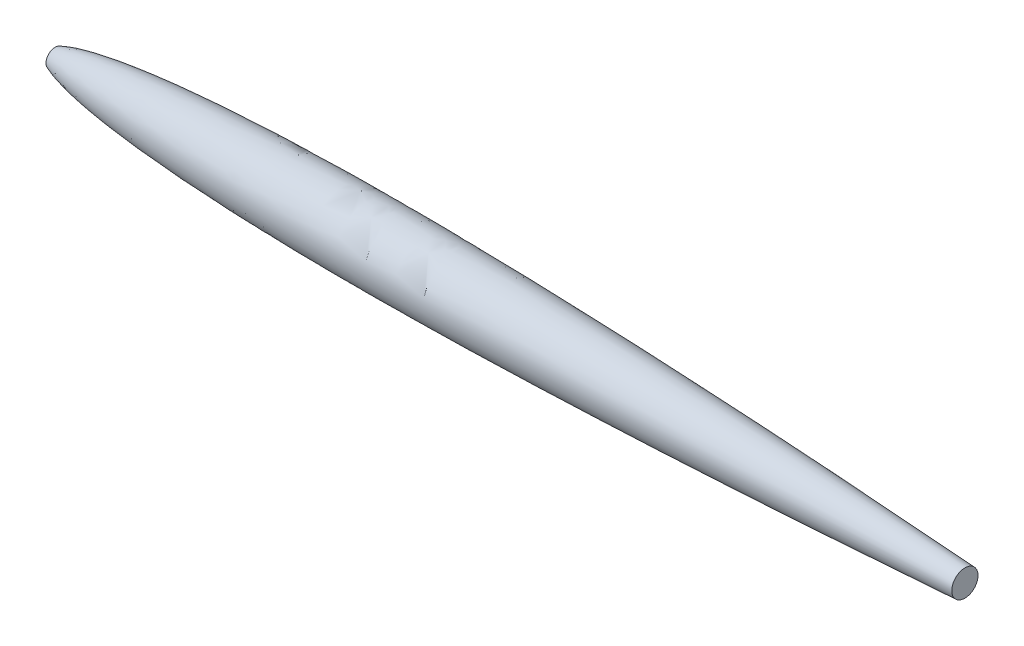
from build123d import *

# Parameters (mm, degrees)
CUTSKETCH_R        = 330
CUT_EXTRUDE1_DEPTH = 1981.000000056
SKETCH1_R          = 330
CUT_EXTRUDE2_DEPTH = 100


with BuildPart() as part:
    # rootSketch → Revolve1 (revolve)
    with BuildSketch(Plane(origin=(0, 0, 0), x_dir=(1, 0, 0), z_dir=(0, 1, 0))):
        with BuildLine():
            Line((0, 0), (10999.999999956, 0))
            add(Edge.make_bspline(
                [(0, 0), (0.000193085, 1.416582005), (0.122535707, 4.240766735), (0.673873379, 8.454686711), (2.109656818, 13.93845879), (4.130019916, 19.114733958), (6.6108994, 23.964322659), (9.99141312, 29.368131534), (13.807367772, 34.371487293), (18.005055091, 39.082436475), (24.006567174, 45.012475537), (32.38394762, 52.235407337), (43.384048479, 60.194382801), (57.076069362, 68.618071155), (73.982979094, 77.724284629), (92.789267205, 86.643497962), (113.957785626, 95.516746756), (137.455558775, 104.311070441), (166.299503437, 114.136034239), (201.291019257, 124.83380424), (243.070199966, 136.204737597), (291.673004407, 147.963968929), (341.243287097, 158.777969553), (390.608018364, 168.603047356), (439.719156269, 177.608967602), (500.651651233, 187.980684512), (573.469223954, 199.282575084), (658.612232457, 211.186619601), (758.084154261, 223.607887379), (859.684753543, 234.995657417), (963.386980877, 245.464526813), (1069.170635517, 255.102838422), (1175.032596375, 263.835414151), (1280.957756037, 271.761542521), (1386.934581972, 278.961621427), (1492.954015963, 285.502236936), (1625.576964573, 292.926255548), (1784.827209806, 300.723903315), (1970.72108882, 308.376208714), (2183.266072594, 315.387382688), (2395.855799019, 320.860371187), (2608.476211675, 324.955727138), (2821.116716449, 327.806853247), (3033.769186051, 329.526860496), (3299.591922937, 330.384071895), (3618.580812409, 329.51376865), (3990.720403141, 326.052290468), (4415.985201528, 319.209100208), (4841.201558049, 309.857365651), (5266.363404579, 298.307410519), (5691.467689334, 284.815055747), (6116.513213618, 269.590680129), (6541.499783516, 252.805736724), (6966.427609798, 234.597307498), (7391.296846876, 215.071528971), (7816.107239786, 194.306117476), (8187.764015612, 175.096544249), (8506.288418891, 157.904884619), (8771.698784382, 143.095088026), (8984.01062255, 130.95609045), (9196.305479291, 118.523403252), (9382.048027901, 107.38440154), (9541.24447253, 97.647382898), (9673.900203702, 89.404934778), (9780.020008578, 82.733097615), (9912.663326878, 74.294734048), (10032.03499694, 66.58027009), (10138.136351112, 59.627723881), (10230.971046534, 53.471278218), (10284.016761583, 49.932402374), (10337.064143493, 46.372127364), (10390.104279802, 42.790919783), (10443.152990441, 39.18744375), (10496.183419271, 35.563459924), (10549.240167305, 31.915530826), (10602.249493916, 28.248814521), (10655.332945198, 24.554271665), (10708.28973189, 20.846283715), (10761.453592237, 17.100380429), (10814.258157127, 13.357501973), (10861.039415372, 10.020132172), (10900.208423325, 7.212345677), (10934.336848159, 4.754530233), (10958.871036751, 2.983522743), (10981.803250473, 1.321442896), (10993.97273069, 0.438031797), (10999.999999956, 0)],
                knots=[0, 0, 0, 0, 0, 0.000464454, 0.000928907, 0.001393361, 0.001857814, 0.002287128, 0.002716441, 0.003486019, 0.003922473, 0.004358926, 0.005488094, 0.007117503, 0.008377929, 0.009638355, 0.011796648, 0.013954941, 0.015918589, 0.017882237, 0.021809533, 0.025977713, 0.030145893, 0.034314073, 0.038482253, 0.042518279, 0.046554305, 0.054626357, 0.062698409, 0.070770462, 0.079497478, 0.088224494, 0.09695151, 0.105678526, 0.114405542, 0.123132558, 0.131859574, 0.14058659, 0.158058513, 0.175530436, 0.193002359, 0.210474282, 0.227946206, 0.24541813, 0.262890054, 0.280361977, 0.315305825, 0.350249672, 0.38519352, 0.420137368, 0.455081215, 0.490025063, 0.524968911, 0.559912758, 0.594856606, 0.629800453, 0.664744301, 0.699688149, 0.717160073, 0.734631996, 0.75210392, 0.769575844, 0.787047768, 0.79578373, 0.804519691, 0.813255653, 0.821991615, 0.839463539, 0.84383152, 0.848199501, 0.852567482, 0.856935463, 0.861303444, 0.865671425, 0.870039406, 0.874407387, 0.878775368, 0.883143349, 0.88751133, 0.891879311, 0.896247292, 0.900615273, 0.902799263, 0.904983254, 0.907167244, 0.909351235, 0.909351235, 0.909351235, 0.909351235, 0.909351235], degree=4))
        make_face()
    revolve(axis=Axis((0, 0, 0), (1, 0, 0)))

    # cutSketch → Cut-Extrude1 (cut, through all)
    with BuildSketch(Plane(origin=(9020, 0, 0), x_dir=(0, 0, -1), z_dir=(1, 0, 0))):
        Circle(CUTSKETCH_R)
    extrude(amount=CUT_EXTRUDE1_DEPTH, mode=Mode.SUBTRACT)

    # Sketch1 → Cut-Extrude2 (cut)
    with BuildSketch(Plane(origin=(0, 0, 0), x_dir=(0, 0, -1), z_dir=(1, 0, 0))):
        Circle(SKETCH1_R)
    extrude(amount=CUT_EXTRUDE2_DEPTH, mode=Mode.SUBTRACT)


solid = part.part
